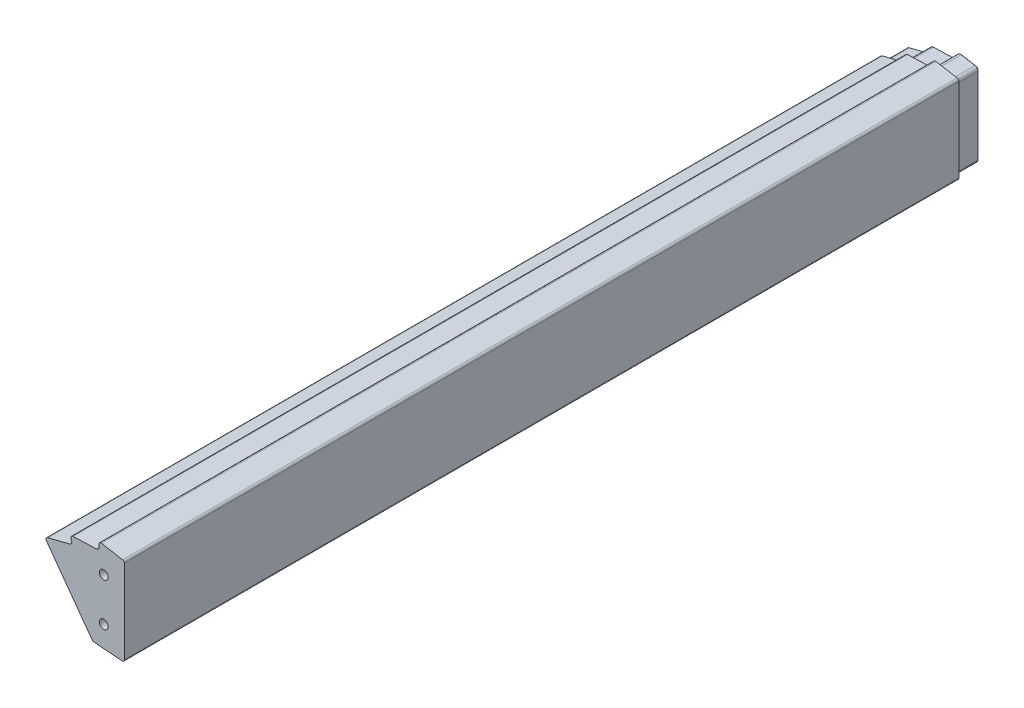
from build123d import *

# Parameters (mm, degrees)
EXTRUDE_THIN1_DEPTH                   = 137.50025
EXTRUDE_THIN1_DEPTH_BACK              = 213.5
BOSS_EXTRUDE1_DEPTH                   = 212.50025
BOSS_EXTRUDE1_DEPTH_BACK              = 288.5
SKETCH3_OUTSIDE_W                     = 604.182
SKETCH3_OUTSIDE_H                     = 156.652
SKETCH3_OUTSIDE_W_2                   = 500
SKETCH3_OUTSIDE_H_2                   = 100
CUT_EXTRUDE1_DEPTH                    = 47.972186303
F_1_4_20_TAPPED_HOLE1_D               = 5.1054
F_1_4_20_TAPPED_HOLE1_DEPTH           = 16.51
F_1_4_20_TAPPED_HOLE1_TIP             = 1.533816902
F_1_4_20_TAPPED_HOLE1_ON_FACE_2_D     = 5.1054
F_1_4_20_TAPPED_HOLE1_ON_FACE_2_DEPTH = 16.51
F_1_4_20_TAPPED_HOLE1_ON_FACE_2_TIP   = 1.533816902
SKETCH5_OUTSIDE_W                     = 148.686
SKETCH5_OUTSIDE_H                     = 156.454
CUT_EXTRUDE2_DEPTH                    = 13
FILLET3_R                             = 2.1
FILLET4_R                             = 2.1
CHAMFER1_SIZE                         = 0.5


with BuildPart() as part:
    # Sketch1 → Extrude-Thin1 (new body, two sides)
    with BuildSketch(Plane.XY) as extrude_thin1_sk:
        with BuildLine():
            Line((-1, 29.097280522), (-1, 77.801426037))
            ThreePointArc((-1, 77.801426037), (-1.350622843, 78.7652373), (-2.238576202, 79.27846957))
            Line((-2.238576202, 79.27846957), (-14.558703222, 81.459024393))
            ThreePointArc((-14.558703222, 81.459024393), (-15.894736772, 81.028505528), (-16.289731153, 79.68154169))
            Line((-16.289731153, 79.68154169), (-16.133756175, 78.918587006))
            ThreePointArc((-16.133756175, 78.918587006), (-16.425245764, 77.689683446), (-17.55197675, 77.119028185))
            Line((-17.55197675, 77.119028185), (-31.176844121, 76.652024665))
            ThreePointArc((-31.176844121, 76.652024665), (-32.394172227, 75.953136676), (-32.500485503, 74.55348328))
            Line((-32.500485503, 74.55348328), (-32.189291755, 73.839630008))
            ThreePointArc((-32.189291755, 73.839630008), (-32.21890818, 72.576976846), (-33.20237149, 71.784531227))
            Line((-33.20237149, 71.784531227), (-46.048094305, 68.590520727))
            ThreePointArc((-46.048094305, 68.590520727), (-47.095522717, 67.648327863), (-46.899674591, 66.2531658))
            Line((-46.899674591, 66.2531658), (-20.221033316, 29.533166286))
            ThreePointArc((-20.221033316, 29.533166286), (-19.7411642, 29.106506164), (-19.126852316, 28.919599404))
            Line((-19.126852316, 28.919599404), (-2.619344492, 27.602035762))
            ThreePointArc((-2.619344492, 27.602035762), (-1.482408908, 27.995233168), (-1, 29.097280522))
        make_face()
        with BuildLine():
            Line((-1.27, 29.097280522), (-1.27, 77.801426037))
            ThreePointArc((-1.27, 77.801426037), (-1.557510731, 78.591751273), (-2.285632486, 79.012601734))
            Line((-2.285632486, 79.012601734), (-14.605759506, 81.193156557))
            ThreePointArc((-14.605759506, 81.193156557), (-15.701307017, 80.840131088), (-16.025202409, 79.735620741))
            Line((-16.025202409, 79.735620741), (-15.869227431, 78.972666057))
            ThreePointArc((-15.869227431, 78.972666057), (-16.213185147, 77.522559856), (-17.542727709, 76.849186648))
            Line((-17.542727709, 76.849186648), (-31.16759508, 76.382183127))
            ThreePointArc((-31.16759508, 76.382183127), (-32.165804128, 75.809094976), (-32.252981014, 74.661379192))
            Line((-32.252981014, 74.661379192), (-31.941787266, 73.94752592))
            ThreePointArc((-31.941787266, 73.94752592), (-31.976734648, 72.457595189), (-33.137221353, 71.522509358))
            Line((-33.137221353, 71.522509358), (-45.982944168, 68.328498858))
            ThreePointArc((-45.982944168, 68.328498858), (-46.841835466, 67.55590071), (-46.681240003, 66.411867819))
            Line((-46.681240003, 66.411867819), (-20.002598727, 29.691868304))
            ThreePointArc((-20.002598727, 29.691868304), (-19.609106053, 29.342007004), (-19.105370308, 29.188743461))
            Line((-19.105370308, 29.188743461), (-2.597862483, 27.871179818))
            ThreePointArc((-2.597862483, 27.871179818), (-1.665575304, 28.193601692), (-1.27, 29.097280522))
        make_face(mode=Mode.SUBTRACT)
    extrude(amount=EXTRUDE_THIN1_DEPTH)
    extrude(extrude_thin1_sk.sketch, amount=-EXTRUDE_THIN1_DEPTH_BACK)


with BuildPart() as body_2:
    # Sketch2 → Boss-Extrude1 (new body, two sides)
    with BuildSketch(Plane.XY) as boss_extrude1_sk:
        with BuildLine():
            Line((-46.68124, 66.411867814), (-20.002598727, 29.691868304))
            ThreePointArc((-20.002598727, 29.691868304), (-19.609106053, 29.342007004), (-19.105370308, 29.188743461))
            Line((-19.105370308, 29.188743461), (-2.597862483, 27.871179818))
            ThreePointArc((-2.597862483, 27.871179818), (-1.665575304, 28.193601692), (-1.27, 29.097280522))
            Line((-1.27, 29.097280522), (-1.27, 77.801426032))
            Line((-1.27, 77.801426032), (-1.27, 77.950492716))
            ThreePointArc((-1.27, 77.950492716), (-1.551343626, 78.723865476), (-2.263847169, 79.135688695))
            Line((-2.263847169, 79.135688695), (-14.583974189, 81.316243518))
            ThreePointArc((-14.583974189, 81.316243518), (-15.79085783, 80.927341477), (-16.14766942, 79.710584143))
            Line((-16.14766942, 79.710584143), (-15.991694442, 78.947629459))
            ThreePointArc((-15.991694442, 78.947629459), (-16.311361359, 77.599931889), (-17.547009673, 76.974113285))
            Line((-17.547009673, 76.974113285), (-31.171877043, 76.507109765))
            ThreePointArc((-31.171877043, 76.507109765), (-32.271530099, 75.875780948), (-32.367566426, 74.611427381))
            Line((-32.367566426, 74.611427381), (-32.056372677, 73.897574109))
            ThreePointArc((-32.056372677, 73.897574109), (-32.088852024, 72.512864474), (-33.167383454, 71.643815779))
            Line((-33.167383454, 71.643815779), (-46.013106268, 68.449805279))
            ThreePointArc((-46.013106268, 68.449805279), (-46.895812164, 67.655785195), (-46.730763849, 66.480031545))
            Line((-46.730763849, 66.480031545), (-46.68124, 66.411867814))
        make_face()
    extrude(amount=BOSS_EXTRUDE1_DEPTH)
    extrude(boss_extrude1_sk.sketch, amount=-BOSS_EXTRUDE1_DEPTH_BACK)

    # Sketch3 outside → Cut-Extrude1 (cut, through all)
    with BuildSketch(Plane(origin=(0, 0, 0), x_dir=(0, 0, -1), z_dir=(1, 0, 0))):
        with Locations((38, 54.602)):
            Rectangle(SKETCH3_OUTSIDE_W, SKETCH3_OUTSIDE_H)
        with Locations((37.999875, 53.523886616)):
            Rectangle(SKETCH3_OUTSIDE_W_2, SKETCH3_OUTSIDE_H_2, mode=Mode.SUBTRACT)
    extrude(amount=-CUT_EXTRUDE1_DEPTH, mode=Mode.SUBTRACT)

    # 1/4-20 Tapped Hole1
    with Locations(Plane(origin=(-13.27, 66.023886616, 212.000125), x_dir=(1, 0, 0), z_dir=(0, 0, 1))):
        with Locations((0, 0), (0, -25)):
            Hole(F_1_4_20_TAPPED_HOLE1_D / 2, depth=F_1_4_20_TAPPED_HOLE1_DEPTH)
            with Locations((0, 0, -(F_1_4_20_TAPPED_HOLE1_DEPTH + F_1_4_20_TAPPED_HOLE1_TIP / 2))):  # 118° drill point
                Cone(0, F_1_4_20_TAPPED_HOLE1_D / 2, F_1_4_20_TAPPED_HOLE1_TIP, mode=Mode.SUBTRACT)

    # 1/4-20 Tapped Hole1 on face 2
    with Locations(Plane(origin=(-13.27, 66.023886616, -287.999875), x_dir=(-1, 0, 0), z_dir=(0, 0, -1))):
        with Locations((0, 0), (0, -25)):
            Hole(F_1_4_20_TAPPED_HOLE1_ON_FACE_2_D / 2, depth=F_1_4_20_TAPPED_HOLE1_ON_FACE_2_DEPTH)
            with Locations((0, 0, -(F_1_4_20_TAPPED_HOLE1_ON_FACE_2_DEPTH + F_1_4_20_TAPPED_HOLE1_ON_FACE_2_TIP / 2))):  # 118° drill point
                Cone(0, F_1_4_20_TAPPED_HOLE1_ON_FACE_2_D / 2, F_1_4_20_TAPPED_HOLE1_ON_FACE_2_TIP, mode=Mode.SUBTRACT)

    # Sketch5 outside → Cut-Extrude2 (cut)
    with BuildSketch(Plane(origin=(0, 0, -287.999875), x_dir=(-1, 0, 0), z_dir=(0, 0, -1))):
        with Locations((24.121, 54.602)):
            Rectangle(SKETCH5_OUTSIDE_W, SKETCH5_OUTSIDE_H)
        with BuildLine():
            Line((2.57, 29.17309026), (18.969817109, 30.482058458))
            Line((18.969817109, 30.482058458), (45.647739584, 67.201068629))
            Line((45.647739584, 67.201068629), (32.853697609, 70.382229004))
            ThreePointArc((32.853697609, 70.382229004), (30.922831311, 71.938063902), (30.864684396, 74.417072944))
            Line((30.864684396, 74.417072944), (31.208213492, 75.205100887))
            Line((31.208213492, 75.205100887), (17.502477256, 75.674876254))
            ThreePointArc((17.502477256, 75.674876254), (15.290328755, 76.79526275), (14.718037528, 79.208010073))
            Line((14.718037528, 79.208010073), (14.890219467, 80.05024143))
            Line((14.890219467, 80.05024143), (2.57, 77.869670245))
            Line((2.57, 77.869670245), (2.57, 29.17309026))
        make_face(mode=Mode.SUBTRACT)
    extrude(amount=-CUT_EXTRUDE2_DEPTH, mode=Mode.SUBTRACT)

    # Fillet3
    fillet3_edges = [body_2.edges().sort_by_distance(p)[0] for p in [
        (-31.208213492, 75.205100887, -281.499875),
    ]]
    fillet(fillet3_edges, radius=FILLET3_R)

    # Fillet4
    fillet4_edges = [body_2.edges().sort_by_distance(p)[0] for p in [
        (-2.57, 29.17309026, -281.499875),
        (-18.969817109, 30.482058458, -281.499875),
        (-2.57, 77.869670245, -281.499875),
        (-45.647739584, 67.201068629, -281.499875),
        (-14.890219467, 80.05024143, -281.499875),
    ]]
    fillet(fillet4_edges, radius=FILLET4_R)

    # Chamfer1
    chamfer1_edges = [body_2.edges().sort_by_distance(p)[0] for p in [
        (-15.720977232, 76.353272794, -287.999875),
        (-31.252174207, 71.416195634, -287.999875),
        (-23.046962204, 75.484834478, -287.999875),
        (-30.023249286, 74.661893082, -287.999875),
        (-2.57, 53.778047874, -287.999875),
        (-8.307997228, 78.885245613, -287.999875),
        (-11.421630112, 29.879592183, -287.999875),
        (-31.677250598, 47.972340168, -287.999875),
        (-37.738977535, 69.167533996, -287.999875),
        (-13.844088825, 79.272536107, -287.999875),
        (-44.090657237, 66.633768979, -287.999875),
        (-3.06087198, 77.458049098, -287.999875),
        (-18.866214572, 30.666814075, -287.999875),
        (-3.245372471, 29.904516124, -287.999875),
    ]]
    chamfer(chamfer1_edges, length=CHAMFER1_SIZE)


solid = body_2.part
